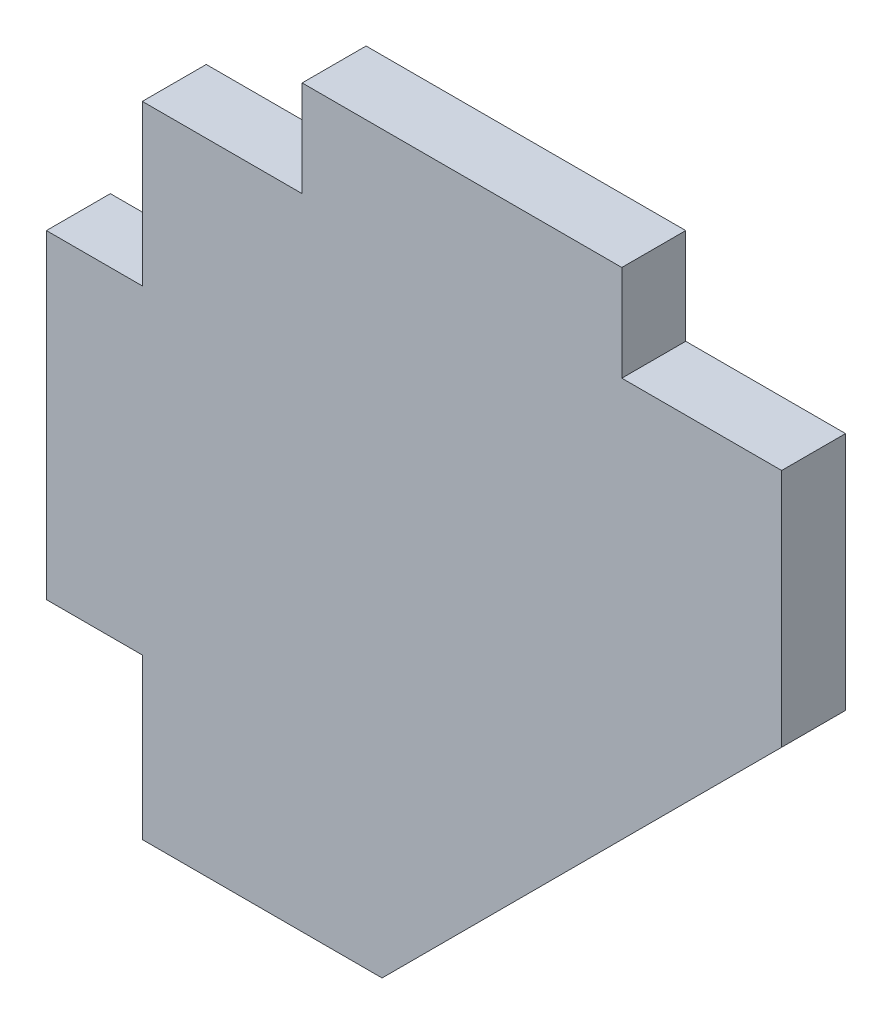
from build123d import *

# Parameters (mm, degrees)
BOSS_EXTRU_1_DEPTH = 4


with BuildPart() as part:
    # Esquisse1 → Boss.-Extru.1 (new body)
    with BuildSketch(Plane.XY):
        Polygon((-2459.723805414, -14), (-2453.723805414, -14), (-2453.723805414, -4), (-2443.723805414, -4), (-2443.723805414, 2), (-2423.723805414, 2), (-2423.723805414, -4), (-2413.723805414, -4), (-2413.723805414, -19), (-2438.723805414, -44), (-2453.723805414, -44), (-2453.723805414, -34), (-2459.723805414, -34), align=None)
    extrude(amount=-BOSS_EXTRU_1_DEPTH)


solid = part.part
